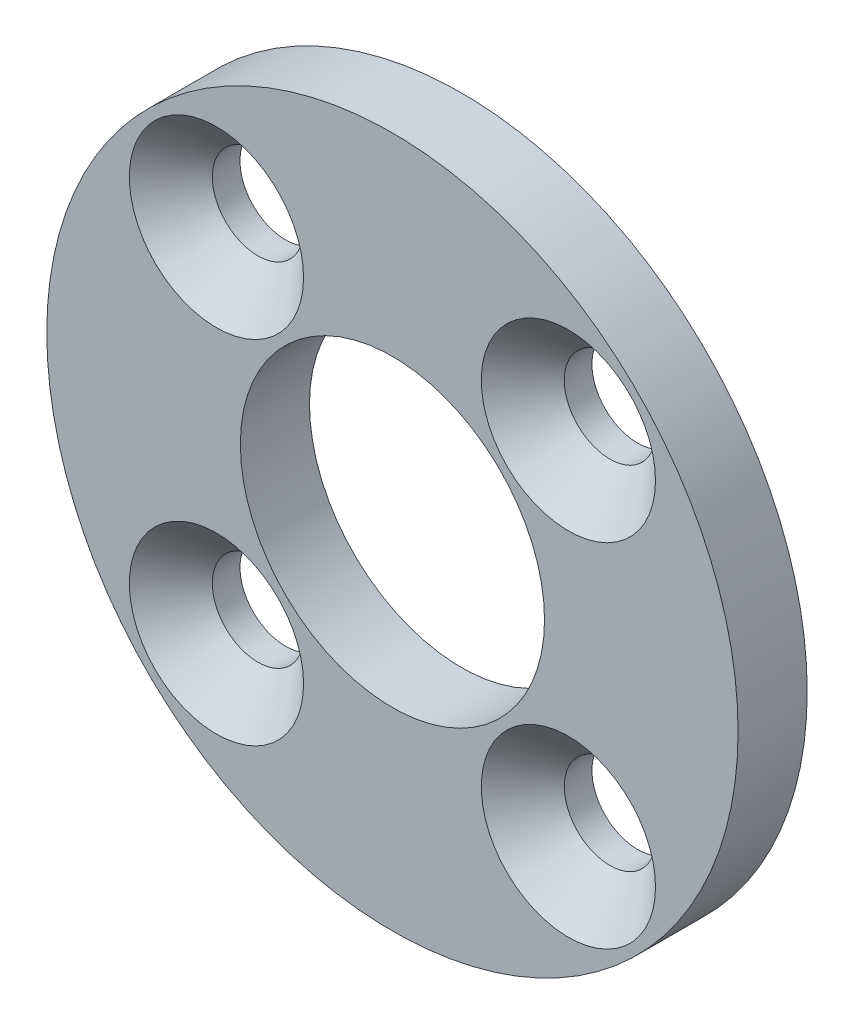
from build123d import *

# Parameters (mm, degrees)
ESQUISSE1_R                                 = 25
BOSS_EXTRU_1_DEPTH                          = 5
ESQUISSE2_R                                 = 11
ENL_V_MAT_EXTRU_1_DEPTH                     = 6
FRAISAGE_POUR_VIS_T_TE_FRAIS_E_M61_AT_COUNT = 2
FRAISAGE_POUR_VIS_T_TE_FRAIS_E_M61_AT_PITCH = 36
FRAISAGE_POUR_VIS_T_TE_FRAIS_E_M61_2_COUNT  = 2
FRAISAGE_POUR_VIS_T_TE_FRAIS_E_M61_2_PITCH  = 25.455844123
FRAISAGE_POUR_VIS_T_TE_FRAIS_E_M61_3_COUNT  = 2
FRAISAGE_POUR_VIS_T_TE_FRAIS_E_M61_3_PITCH  = 25.455844123


with BuildPart() as part:
    # Esquisse1 → Boss.-Extru.1 (new body)
    with BuildSketch(Plane.XY):
        Circle(ESQUISSE1_R)
    extrude(amount=BOSS_EXTRU_1_DEPTH)

    # Esquisse2 → Enlèv. mat.-Extru.1 (cut, through all)
    with BuildSketch(Plane.XY.offset(5)):
        Circle(ESQUISSE2_R)
    extrude(amount=-ENL_V_MAT_EXTRU_1_DEPTH, mode=Mode.SUBTRACT)

    # Esquisse8 → Fraisage pour vis à tête fraisée M61 (revolve, cut)
    with BuildSketch(Plane(origin=(12.727922061, 12.727922061, 5), x_dir=(0, -1, 0), z_dir=(1, 0, 0))):
        Polygon((0, 0), (0, 5), (3.3, 5), (3.3, 3), (6.3, 0), align=None)
    fraisage_pour_vis_t_te_frais_e_m61 = revolve(axis=Axis((12.727922061, 12.727922061, 11.35), (0, 0, -1)), mode=Mode.SUBTRACT)

    # Fraisage pour vis à tête fraisée M61 at: Fraisage pour vis à tête fraisée M61 ×2
    with Locations(*[Vector(-0.707106781, -0.707106781, 0) * (i * FRAISAGE_POUR_VIS_T_TE_FRAIS_E_M61_AT_PITCH) for i in range(1, FRAISAGE_POUR_VIS_T_TE_FRAIS_E_M61_AT_COUNT)]):
        add(fraisage_pour_vis_t_te_frais_e_m61, mode=Mode.SUBTRACT)

    # Fraisage pour vis _ t_te frais_e M61 2: Fraisage pour vis à tête fraisée M61 ×2
    with Locations(*[(-i * FRAISAGE_POUR_VIS_T_TE_FRAIS_E_M61_2_PITCH, 0, 0) for i in range(1, FRAISAGE_POUR_VIS_T_TE_FRAIS_E_M61_2_COUNT)]):
        add(fraisage_pour_vis_t_te_frais_e_m61, mode=Mode.SUBTRACT)

    # Fraisage pour vis _ t_te frais_e M61 3: Fraisage pour vis à tête fraisée M61 ×2
    with Locations(*[(0, -i * FRAISAGE_POUR_VIS_T_TE_FRAIS_E_M61_3_PITCH, 0) for i in range(1, FRAISAGE_POUR_VIS_T_TE_FRAIS_E_M61_3_COUNT)]):
        add(fraisage_pour_vis_t_te_frais_e_m61, mode=Mode.SUBTRACT)


solid = part.part
